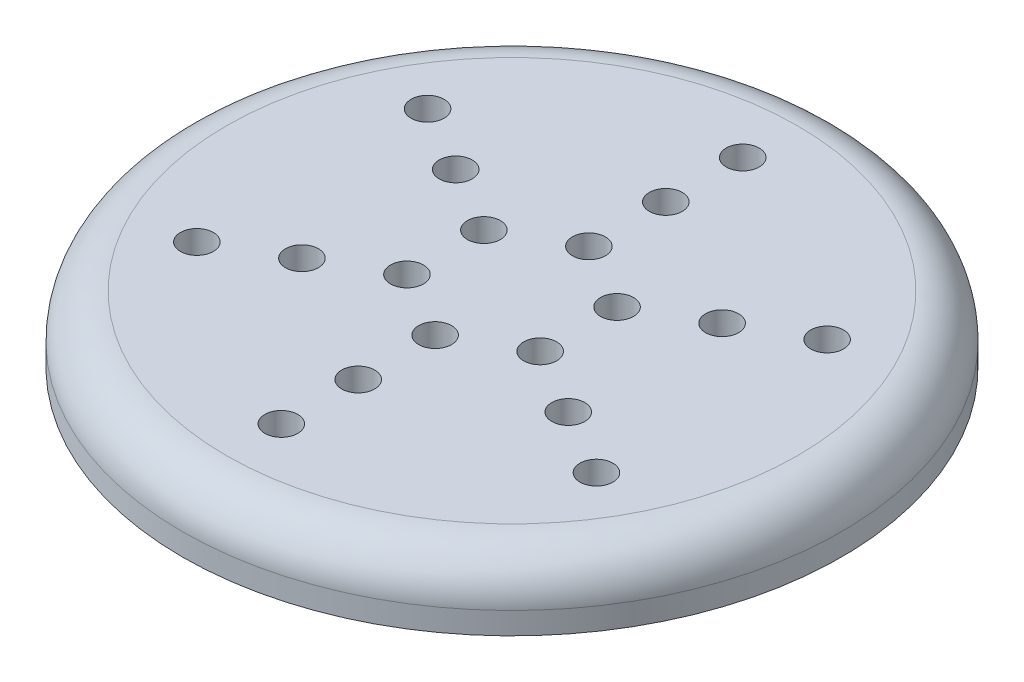
from build123d import *

# Parameters (mm, degrees)
SKETCH1_R           = 15
SKETCH1_R_2         = 0.75
BOSS_EXTRUDE1_DEPTH = 3
FILLET1_R           = 2


with BuildPart() as part:
    # Sketch1 → Boss-Extrude1 (new body)
    with BuildSketch(Plane(origin=(0, 0, 0), x_dir=(1, 0, 0), z_dir=(0, 1, 0))):
        Circle(SKETCH1_R)
        with Locations((0, 10.5)):
            Circle(SKETCH1_R_2, mode=Mode.SUBTRACT)
        with Locations((0, 7)):
            Circle(SKETCH1_R_2, mode=Mode.SUBTRACT)
        with Locations((0, 3.5)):
            Circle(SKETCH1_R_2, mode=Mode.SUBTRACT)
        with Locations((3.031088913, 1.75)):
            Circle(SKETCH1_R_2, mode=Mode.SUBTRACT)
        with Locations((6.062177826, 3.5)):
            Circle(SKETCH1_R_2, mode=Mode.SUBTRACT)
        with Locations((9.09326674, 5.25)):
            Circle(SKETCH1_R_2, mode=Mode.SUBTRACT)
        with Locations((3.031088913, -1.75)):
            Circle(SKETCH1_R_2, mode=Mode.SUBTRACT)
        with Locations((6.062177826, -3.5)):
            Circle(SKETCH1_R_2, mode=Mode.SUBTRACT)
        with Locations((9.09326674, -5.25)):
            Circle(SKETCH1_R_2, mode=Mode.SUBTRACT)
        with Locations((0, -3.5)):
            Circle(SKETCH1_R_2, mode=Mode.SUBTRACT)
        with Locations((0, -7)):
            Circle(SKETCH1_R_2, mode=Mode.SUBTRACT)
        with Locations((0, -10.5)):
            Circle(SKETCH1_R_2, mode=Mode.SUBTRACT)
        with Locations((-3.031088913, -1.75)):
            Circle(SKETCH1_R_2, mode=Mode.SUBTRACT)
        with Locations((-6.062177826, -3.5)):
            Circle(SKETCH1_R_2, mode=Mode.SUBTRACT)
        with Locations((-9.09326674, -5.25)):
            Circle(SKETCH1_R_2, mode=Mode.SUBTRACT)
        with Locations((-3.031088913, 1.75)):
            Circle(SKETCH1_R_2, mode=Mode.SUBTRACT)
        with Locations((-6.062177826, 3.5)):
            Circle(SKETCH1_R_2, mode=Mode.SUBTRACT)
        with Locations((-9.09326674, 5.25)):
            Circle(SKETCH1_R_2, mode=Mode.SUBTRACT)
    extrude(amount=BOSS_EXTRUDE1_DEPTH)

    # Fillet1
    fillet1_edges = [part.edges().sort_by_distance(p)[0] for p in [
        (-15, 3, 0),
    ]]
    fillet(fillet1_edges, radius=FILLET1_R)


solid = part.part
